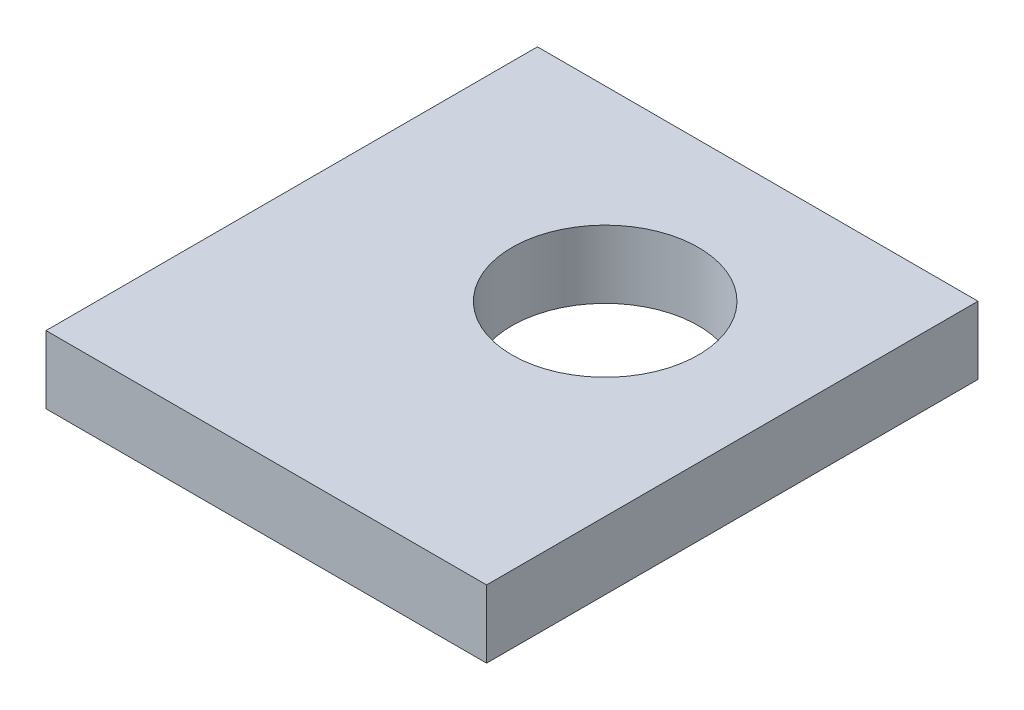
from build123d import *

# Parameters (mm, degrees)
SKETCH_1_W      = 26
SKETCH_1_H      = 29
SKETCH_1_R      = 5.5
EXTRUDE_1_DEPTH = 4


with BuildPart() as part:
    # Эскиз1 → Бобышка-Вытянуть1 (new body)
    with BuildSketch(Plane(origin=(0, 0, 0), x_dir=(1, 0, 0), z_dir=(0, 1, 0))):
        with Locations((13, 14.5)):
            Rectangle(SKETCH_1_W, SKETCH_1_H)
        with Locations((15, 18)):
            Circle(SKETCH_1_R, mode=Mode.SUBTRACT)
    extrude(amount=EXTRUDE_1_DEPTH)


solid = part.part
